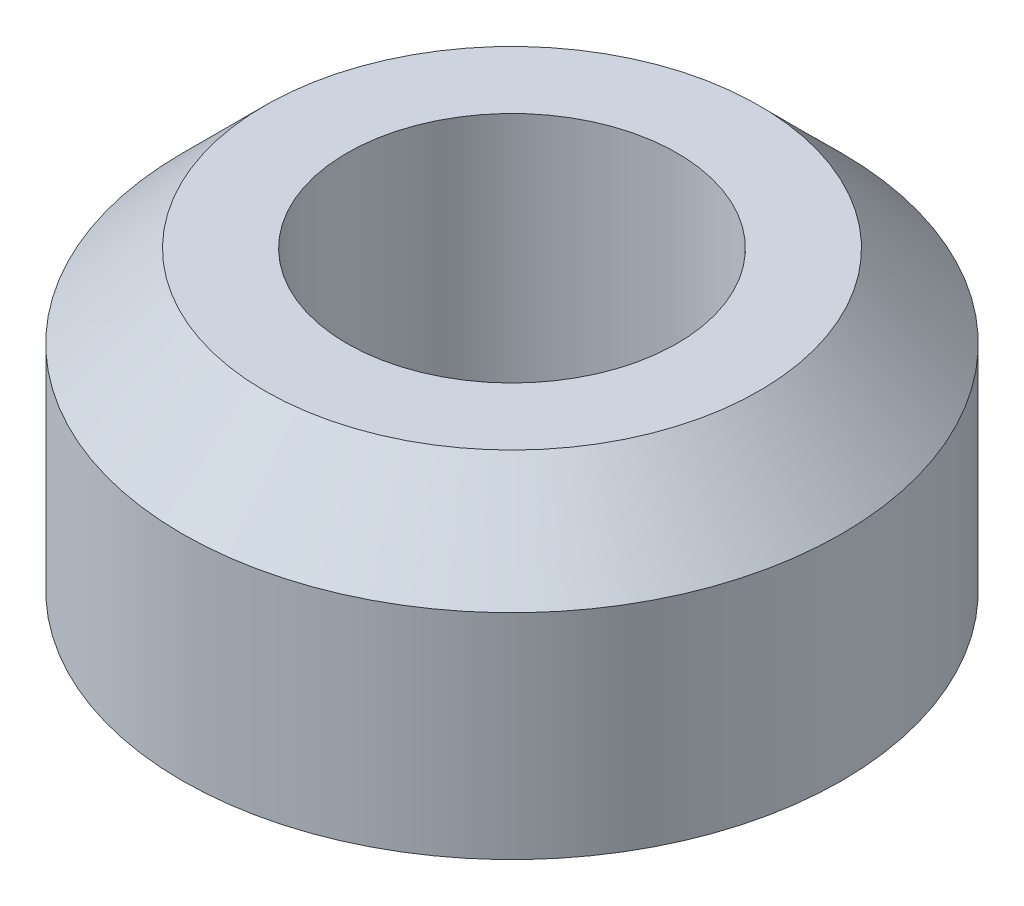
from build123d import *


with BuildPart() as part:
    # Sketch1 → Revolve1 (revolve)
    with BuildSketch(Plane.XY):
        Polygon((3.175, 0.325), (6.341677617, 0.325), (6.341677617, 4.4375), (4.754177617, 6.025), (3.175, 6.025), align=None)
    revolve(axis=Axis((0, 6.35, 0), (0, -1, 0)))


solid = part.part
